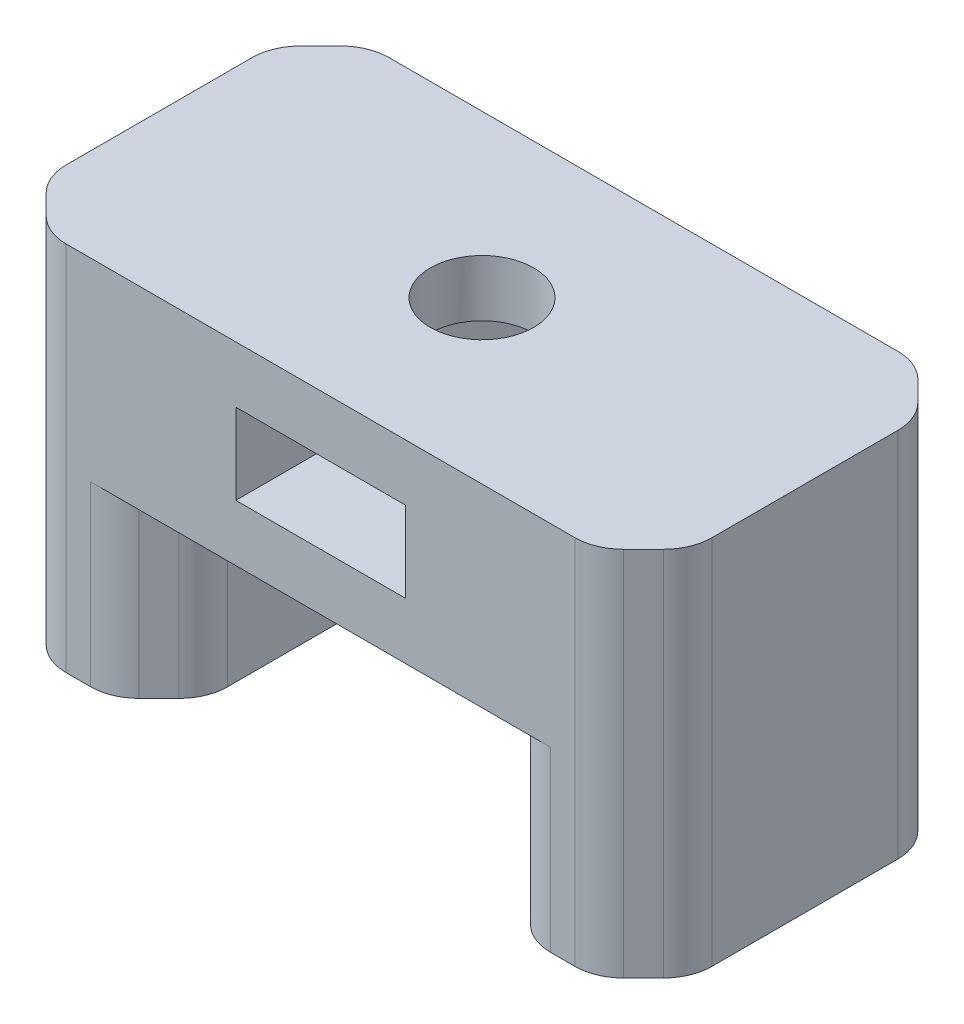
from build123d import *

# Parameters (mm, degrees)
ESQUISSE1_W             = 10
ESQUISSE1_H             = 20
BOSS_EXTRU_1_DEPTH      = 11
BOSS_EXTRU_1_2_DEPTH    = 11
ESQUISSE3_W             = 40
ESQUISSE3_H             = 20
BOSS_EXTRU_2_DEPTH      = 12
ESQUISSE4_R             = 3.2
ENL_V_MAT_EXTRU_1_DEPTH = 12
ESQUISSE1_3_R           = 2
ENL_V_MAT_EXTRU_3_DEPTH = 15
CHANFREIN1_SIZE         = 3
CONG_1_R                = 3
ESQUISSE6_W             = 10.5
ESQUISSE6_H             = 20
ENL_V_MAT_EXTRU_5_DEPTH = 5


with BuildPart() as part:
    # Esquisse1 → Boss.-Extru.1 (new body)
    with BuildSketch(Plane(origin=(0, 0, 0), x_dir=(1, 0, 0), z_dir=(0, 1, 0))):
        with Locations((-15, 0)):
            Rectangle(ESQUISSE1_W, ESQUISSE1_H)
    extrude(amount=BOSS_EXTRU_1_DEPTH)



with BuildPart() as body_2:
    # Esquisse1 → Boss.-Extru.1 2 (new body)
    with BuildSketch(Plane(origin=(0, 0, 0), x_dir=(1, 0, 0), z_dir=(0, 1, 0))):
        with Locations((15, 0)):
            Rectangle(ESQUISSE1_W, ESQUISSE1_H)
    extrude(amount=BOSS_EXTRU_1_2_DEPTH)


with BuildPart() as part_1:
    add(part.part)

    add(body_2.part)  # Boss.-Extru.2 merges body 2
    # Esquisse3 → Boss.-Extru.2 (add)
    with BuildSketch(Plane(origin=(0, 11, 0), x_dir=(1, 0, 0), z_dir=(0, 1, 0))):
        Rectangle(ESQUISSE3_W, ESQUISSE3_H)
    extrude(amount=BOSS_EXTRU_2_DEPTH)

    # Esquisse4 → Enl_v. mat.-Extru.1 (cut)
    with BuildSketch(Plane(origin=(0, 23, 0), x_dir=(1, 0, 0), z_dir=(0, 1, 0))):
        Circle(ESQUISSE4_R)
    extrude(amount=-ENL_V_MAT_EXTRU_1_DEPTH, mode=Mode.SUBTRACT)

    # Esquisse1_3 → Enl_v. mat.-Extru.3 (cut)
    with BuildSketch(Plane(origin=(0, 0, 0), x_dir=(1, 0, 0), z_dir=(0, 1, 0))):
        with Locations((-15, 0)):
            Circle(ESQUISSE1_3_R)
        with Locations((15, 0)):
            Circle(ESQUISSE1_3_R)
    extrude(amount=ENL_V_MAT_EXTRU_3_DEPTH, mode=Mode.SUBTRACT)

    # Chanfrein1
    chanfrein1_edges = [part_1.edges().sort_by_distance(p)[0] for p in [
        (20, 11.5, 10),
        (20, 11.5, -10),
        (10, 5.5, -10),
        (10, 5.5, 10),
        (-20, 11.5, 10),
        (-20, 11.5, -10),
        (-10, 5.5, -10),
        (-10, 5.5, 10),
    ]]
    chamfer(chanfrein1_edges, length=CHANFREIN1_SIZE)

    # Cong_1
    cong_1_edges = [part_1.edges().sort_by_distance(p)[0] for p in [
        (10, 5.5, 7),
        (10, 5.5, -7),
        (-17, 11.5, -10),
        (-13, 5.5, -10),
        (17, 11.5, -10),
        (13, 5.5, -10),
        (20, 11.5, 7),
        (20, 11.5, -7),
        (-17, 11.5, 10),
        (17, 11.5, 10),
        (-13, 5.5, 10),
        (13, 5.5, 10),
        (-10, 5.5, 7),
        (-10, 5.5, -7),
        (-20, 11.5, 7),
        (-20, 11.5, -7),
    ]]
    fillet(cong_1_edges, radius=CONG_1_R)

    # Esquisse6 → Enl_v. mat.-Extru.5 (cut)
    with BuildSketch(Plane(origin=(0, 14.5, 0), x_dir=(-1, 0, 0), z_dir=(0, -1, 0))):
        Rectangle(ESQUISSE6_W, ESQUISSE6_H)
    extrude(amount=-ENL_V_MAT_EXTRU_5_DEPTH, mode=Mode.SUBTRACT)


solid = part_1.part
